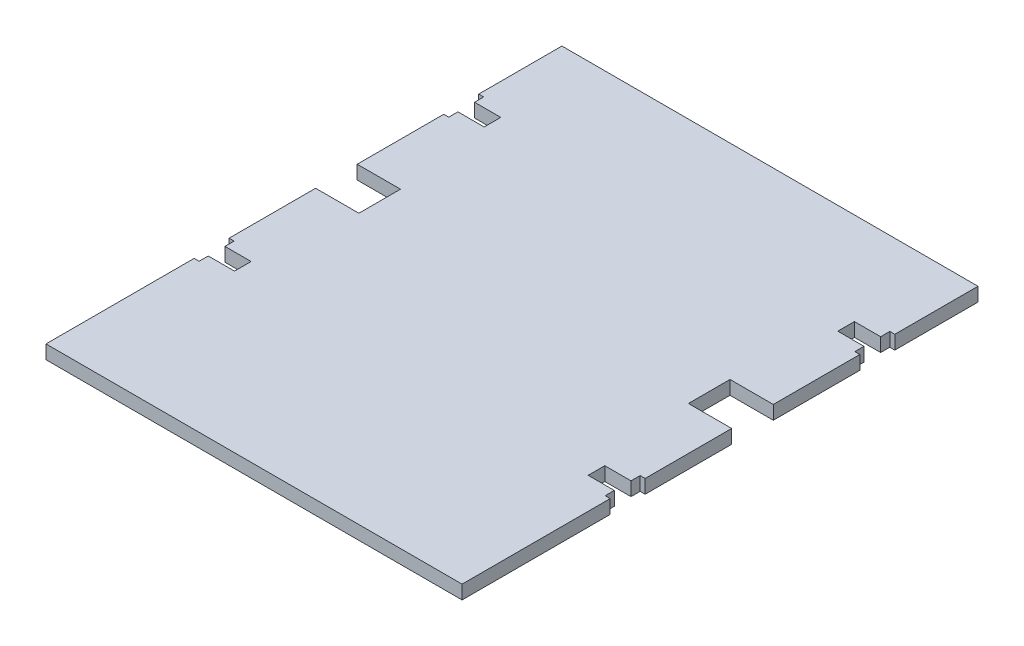
from build123d import *

# Parameters (mm, degrees)
SKETCH1_W           = 500
SKETCH1_H           = 620
BOSS_EXTRUDE1_DEPTH = 16.5
SKETCH2_W           = 52
SKETCH2_H           = 50
CUT_EXTRUDE1_DEPTH  = 17.5


with BuildPart() as part:
    # Sketch1 → Boss-Extrude1 (new body)
    with BuildSketch(Plane(origin=(0, 0, 0), x_dir=(1, 0, 0), z_dir=(0, 1, 0))):
        Rectangle(SKETCH1_W, SKETCH1_H)
    extrude(amount=BOSS_EXTRUDE1_DEPTH)

    # Sketch2 → Cut-Extrude1 (cut, through all)
    with BuildSketch(Plane(origin=(0, 16.5, 0), x_dir=(1, 0, 0), z_dir=(0, 1, 0))):
        with Locations((-224, 39)):
            Rectangle(SKETCH2_W, SKETCH2_H)
        with Locations((224, 39)):
            Rectangle(SKETCH2_W, SKETCH2_H)
        Polygon((-250, 210), (-244, 210), (-244, 199), (-212.5, 199), (-212.5, 179), (-244, 179), (-244, 168), (-250, 168), align=None)
        Polygon((212.5, 199), (212.5, 179), (244, 179), (244, 168), (250, 168), (250, 210), (244, 210), (244, 199), align=None)
        Polygon((212.5, -101), (212.5, -121), (244, -121), (244, -132), (250, -132), (250, -90), (244, -90), (244, -101), align=None)
        Polygon((-250, -90), (-244, -90), (-244, -101), (-212.5, -101), (-212.5, -121), (-244, -121), (-244, -132), (-250, -132), align=None)
    extrude(amount=-CUT_EXTRUDE1_DEPTH, mode=Mode.SUBTRACT)


solid = part.part
